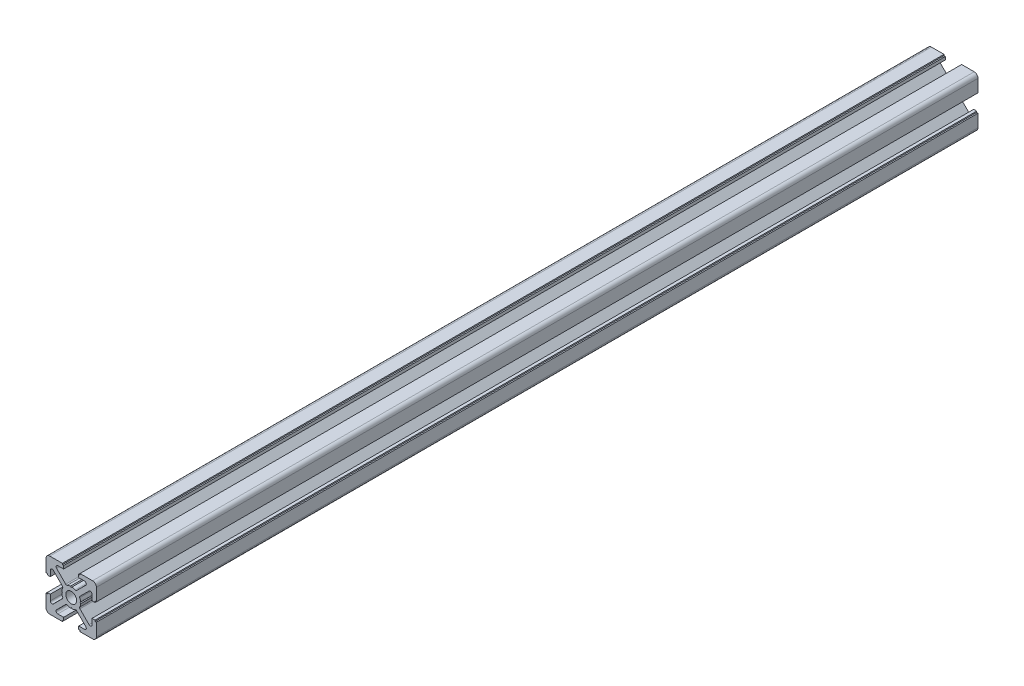
from build123d import *

# Parameters (mm, degrees)
SALIENTE_EXTRUIR1_DEPTH = 350


with BuildPart() as part:
    # Model → Saliente-Extruir1 (new body)
    with BuildSketch(Plane.XY):
        with BuildLine():
            Line((-3.499999575, -9.499999701), (-3.499999575, -9.999999682))
            Line((-3.499999575, -9.999999682), (-8.499999389, -9.999999682))
            ThreePointArc((-8.499999389, -9.999999682), (-9.560659521, -9.56065987), (-9.999999333, -8.499999738))
            Line((-9.999999333, -8.499999738), (-9.999999333, -3.499999924))
            Line((-9.999999333, -3.499999924), (-9.499999352, -3.499999924))
            Line((-9.499999352, -3.499999924), (-9.499999352, -2.999999943))
            Line((-9.499999352, -2.999999943), (-8.299999404, -2.999999943))
            Line((-8.299999404, -2.999999943), (-8.299999404, -5.299390189))
            ThreePointArc((-8.299999404, -5.299390189), (-7.867877821, -5.946105837), (-7.1050247, -5.794364915))
            Line((-7.1050247, -5.794364915), (-3.486125369, -2.175465583))
            ThreePointArc((-3.486125369, -2.175465583), (-3.377738998, -2.013253915), (-3.339678766, -1.821912207))
            ThreePointArc((-3.339678766, -1.821912207), (-3.351896436, -1.712055945), (-3.38795236, -1.607568434))
            ThreePointArc((-3.38795236, -1.607568434), (-3.62245257, -0.969708302), (-3.737980238, -0.299999966))
            Line((-3.737980238, -0.299999966), (-3.449999511, 2.3e-08))
            Line((-3.449999511, 2.3e-08), (-3.737980238, 0.300000012))
            ThreePointArc((-3.737980238, 0.300000012), (-3.622452342, 0.969708679), (-3.387951787, 1.607569073))
            ThreePointArc((-3.387951787, 1.607569073), (-3.351896115, 1.712056255), (-3.339678532, 1.821912131))
            ThreePointArc((-3.339678532, 1.821912131), (-3.377738764, 2.013253839), (-3.486125135, 2.175465507))
            Line((-3.486125135, 2.175465507), (-7.105024467, 5.794364839))
            ThreePointArc((-7.105024467, 5.794364839), (-7.867877588, 5.946105761), (-8.29999917, 5.299390113))
            Line((-8.29999917, 5.299390113), (-8.29999917, 2.999999906))
            Line((-8.29999917, 2.999999906), (-9.499999593, 2.999999906))
            Line((-9.499999593, 2.999999906), (-9.499999593, 3.499999887))
            Line((-9.499999593, 3.499999887), (-9.999999574, 3.499999887))
            Line((-9.999999574, 3.499999887), (-9.999999574, 8.499999701))
            ThreePointArc((-9.999999574, 8.499999701), (-9.560659762, 9.560659833), (-8.49999963, 9.999999645))
            Line((-8.49999963, 9.999999645), (-3.499999816, 9.999999645))
            Line((-3.499999816, 9.999999645), (-3.499999816, 9.499999664))
            Line((-3.499999816, 9.499999664), (-2.999999429, 9.499999664))
            Line((-2.999999429, 9.499999664), (-2.999999429, 8.299999713))
            Line((-2.999999429, 8.299999713), (-5.299389679, 8.299999713))
            ThreePointArc((-5.299389679, 8.299999713), (-5.794364493, 8.094974382), (-5.999389653, 7.599999496))
            ThreePointArc((-5.999389653, 7.599999496), (-5.946105282, 7.332121235), (-5.794364409, 7.105025012))
            Line((-5.794364409, 7.105025012), (-2.175465068, 3.486125671))
            ThreePointArc((-2.175465068, 3.486125671), (-1.907084002, 3.346986792), (-1.607568017, 3.387952613))
            ThreePointArc((-1.607568017, 3.387952613), (-0.969707896, 3.622452871), (-0.299999565, 3.737980599))
            Line((-0.299999565, 3.737980599), (4.24e-07, 3.449999872))
            Line((4.24e-07, 3.449999872), (0.300000413, 3.737980599))
            ThreePointArc((0.300000413, 3.737980599), (0.969709153, 3.622452763), (1.607569631, 3.387952251))
            ThreePointArc((1.607569631, 3.387952251), (1.907085269, 3.346986863), (2.175465919, 3.486125671))
            Line((2.175465919, 3.486125671), (5.794365261, 7.105025012))
            ThreePointArc((5.794365261, 7.105025012), (5.94610618, 7.332121347), (5.999390505, 7.599999739))
            ThreePointArc((5.999390505, 7.599999739), (5.794365259, 8.094974467), (5.299390531, 8.299999713))
            Line((5.299390531, 8.299999713), (3.000000281, 8.299999713))
            Line((3.000000281, 8.299999713), (3.000000281, 9.499999668))
            Line((3.000000281, 9.499999668), (3.500000262, 9.499999668))
            Line((3.500000262, 9.499999668), (3.500000262, 9.99999965))
            Line((3.500000262, 9.99999965), (8.500000076, 9.99999965))
            ThreePointArc((8.500000076, 9.99999965), (9.560660208, 9.560659838), (10.00000002, 8.499999705))
            Line((10.00000002, 8.499999705), (10.00000002, 3.499999793))
            Line((10.00000002, 3.499999793), (9.499999853, 3.499999793))
            Line((9.499999853, 3.499999793), (9.499999853, 2.999999811))
            Line((9.499999853, 2.999999811), (8.299999905, 2.999999811))
            Line((8.299999905, 2.999999811), (8.299999905, 5.299390058))
            ThreePointArc((8.299999905, 5.299390058), (7.867878323, 5.946105706), (7.105025201, 5.794364783))
            Line((7.105025201, 5.794364783), (3.48612587, 2.175465452))
            ThreePointArc((3.48612587, 2.175465452), (3.377739466, 2.013253704), (3.339679267, 1.821911902))
            ThreePointArc((3.339679267, 1.821911902), (3.351896813, 1.712056363), (3.387952305, 1.607569476))
            ThreePointArc((3.387952305, 1.607569476), (3.622453002, 0.969708895), (3.73798096, 0.300000012))
            Line((3.73798096, 0.300000012), (3.450000233, 2.3e-08))
            Line((3.450000233, 2.3e-08), (3.73798096, -0.299999967))
            ThreePointArc((3.73798096, -0.299999967), (3.622453128, -0.969708902), (3.387952538, -1.607569553))
            ThreePointArc((3.387952538, -1.607569553), (3.351897009, -1.712056609), (3.339679501, -1.821912325))
            ThreePointArc((3.339679501, -1.821912325), (3.377739766, -2.01325394), (3.486126104, -2.175465528))
            Line((3.486126104, -2.175465528), (7.105025435, -5.79436486))
            ThreePointArc((7.105025435, -5.79436486), (7.867878557, -5.946105782), (8.300000139, -5.299390134))
            Line((8.300000139, -5.299390134), (8.300000139, -2.999999888))
            Line((8.300000139, -2.999999888), (9.500000087, -2.999999888))
            Line((9.500000087, -2.999999888), (9.500000087, -3.499999869))
            Line((9.500000087, -3.499999869), (10.000000005, -3.499999869))
            Line((10.000000005, -3.499999869), (10.000000005, -8.499999639))
            ThreePointArc((10.000000005, -8.499999639), (9.560660193, -9.560659771), (8.500000061, -9.999999583))
            Line((8.500000061, -9.999999583), (3.500000247, -9.999999583))
            Line((3.500000247, -9.999999583), (3.500000247, -9.499999602))
            Line((3.500000247, -9.499999602), (3.000000266, -9.499999602))
            Line((3.000000266, -9.499999602), (3.000000266, -8.299999646))
            Line((3.000000266, -8.299999646), (5.299390515, -8.299999646))
            ThreePointArc((5.299390515, -8.299999646), (5.794365244, -8.094974401), (5.999390489, -7.599999672))
            ThreePointArc((5.999390489, -7.599999672), (5.946106165, -7.332121281), (5.794365245, -7.105024946))
            Line((5.794365245, -7.105024946), (2.175465904, -3.486125604))
            ThreePointArc((2.175465904, -3.486125604), (1.907086046, -3.346986934), (1.607571067, -3.387951495))
            ThreePointArc((1.607571067, -3.387951495), (0.969709928, -3.622452532), (0.300000413, -3.737980599))
            Line((0.300000413, -3.737980599), (4.24e-07, -3.449999872))
            Line((4.24e-07, -3.449999872), (-0.299999565, -3.737980599))
            ThreePointArc((-0.299999565, -3.737980599), (-0.969708386, -3.622452718), (-1.607568921, -3.38795211))
            ThreePointArc((-1.607568921, -3.38795211), (-1.907084488, -3.346986812), (-2.175465053, -3.486125604))
            Line((-2.175465053, -3.486125604), (-5.794364394, -7.105024946))
            ThreePointArc((-5.794364394, -7.105024946), (-5.94610536, -7.332121393), (-5.999389638, -7.599999915))
            ThreePointArc((-5.999389638, -7.599999915), (-5.794364307, -8.094974487), (-5.299389664, -8.299999647))
            Line((-5.299389664, -8.299999647), (-2.999999594, -8.299999647))
            Line((-2.999999594, -8.299999647), (-2.999999594, -9.499999701))
            Line((-2.999999594, -9.499999701), (-3.499999575, -9.499999701))
        make_face()
        with BuildLine():
            ThreePointArc((-2.149999494, -7.27e-07), (7.98e-07, -2.150000275), (2.150000346, 1.7e-08))
            ThreePointArc((2.150000346, 1.7e-08), (5.3e-08, 2.149999565), (-2.149999494, -7.27e-07))
        make_face(mode=Mode.SUBTRACT)
    extrude(amount=SALIENTE_EXTRUIR1_DEPTH)


solid = part.part
